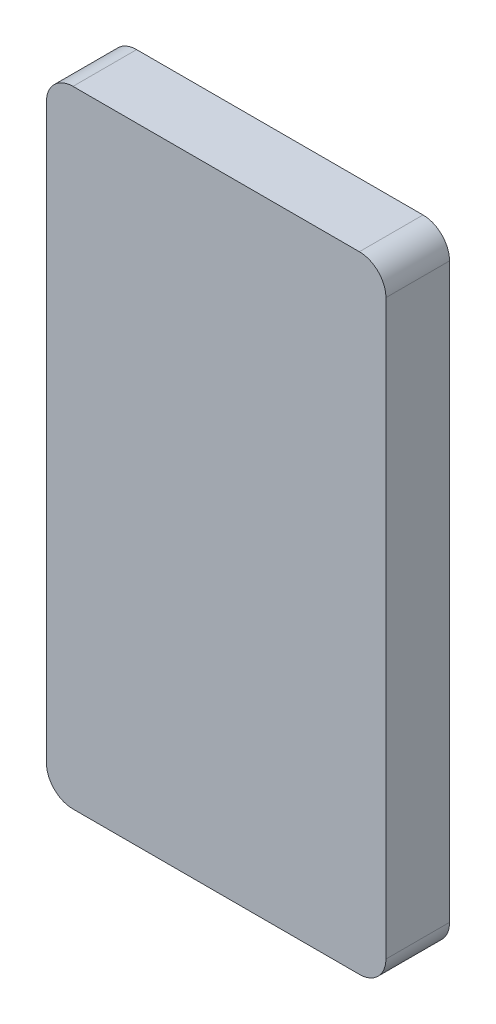
from build123d import *

# Parameters (mm, degrees)
BOSS_EXTRUDE1_DEPTH = 12
SKETCH2_W           = 2.8
SKETCH2_H           = 7.3
CUT_EXTRUDE1_DEPTH  = 10


with BuildPart() as part:
    # Sketch1 → Boss-Extrude1 (new body)
    with BuildSketch(Plane.XY):
        with BuildLine():
            Line((5, 0), (59, 0))
            ThreePointArc((59, 0), (62.535533906, 1.464466094), (64, 5))
            Line((64, 5), (64, 113))
            ThreePointArc((64, 113), (62.535533906, 116.535533906), (59, 118))
            Line((59, 118), (5, 118))
            ThreePointArc((5, 118), (1.464466094, 116.535533906), (0, 113))
            Line((0, 113), (0, 5))
            ThreePointArc((0, 5), (1.464466094, 1.464466094), (5, 0))
        make_face()
    extrude(amount=-BOSS_EXTRUDE1_DEPTH)

    # Sketch2 → Cut-Extrude1 (cut)
    with BuildSketch(Plane(origin=(0, 0, 0), x_dir=(0, 0, -1), z_dir=(1, 0, 0))):
        with Locations((6, 32.5)):
            Rectangle(SKETCH2_W, SKETCH2_H)
    extrude(amount=CUT_EXTRUDE1_DEPTH, mode=Mode.SUBTRACT)


solid = part.part
